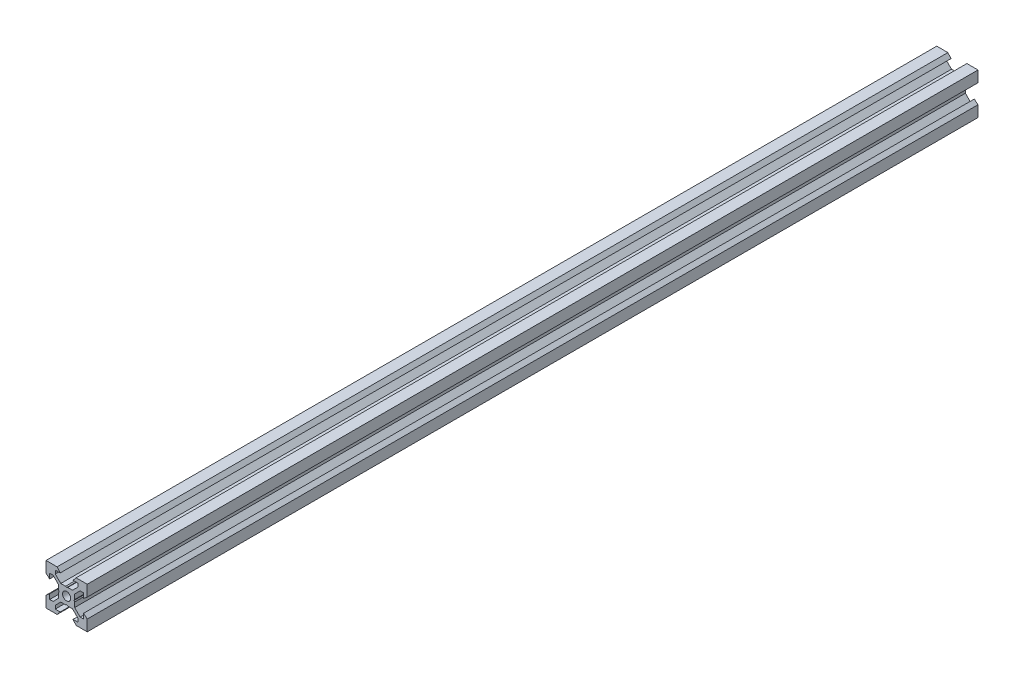
from build123d import *

# Parameters (mm, degrees)
SKETCH1_R           = 2
BOSS_EXTRUDE1_DEPTH = 216


with BuildPart() as part:
    # Sketch1 → Boss-Extrude1 (new body, symmetric)
    with BuildSketch(Plane.XY):
        Polygon((10, 10), (10, 4.610379336), (8.2, 3.1), (8.2, 5.5), (6.560660172, 5.5), (3.9, 2.839339828), (3.9, 0.519615242), (3.6, 0), (3.9, -0.519615242), (3.9, -2.839339828), (6.560660172, -5.5), (8.2, -5.5), (8.2, -3.1), (10, -4.610379336), (10, -10), (4.610379336, -10), (3.1, -8.2), (5.5, -8.2), (5.5, -6.560660172), (2.839339828, -3.9), (0.519615242, -3.9), (0, -3.6), (-0.519615242, -3.9), (-2.839339828, -3.9), (-5.5, -6.560660172), (-5.5, -8.2), (-3.1, -8.2), (-4.610379336, -10), (-10, -10), (-10, -4.610379336), (-8.2, -3.1), (-8.2, -5.5), (-6.560660172, -5.5), (-3.9, -2.839339828), (-3.9, -0.519615242), (-3.6, 0), (-3.9, 0.519615242), (-3.9, 2.839339828), (-6.560660172, 5.5), (-8.2, 5.5), (-8.2, 3.1), (-10, 4.610379336), (-10, 10), (-4.610379336, 10), (-3.1, 8.2), (-5.5, 8.2), (-5.5, 6.560660172), (-2.839339828, 3.9), (-0.519615242, 3.9), (0, 3.6), (0.519615242, 3.9), (2.839339828, 3.9), (5.5, 6.560660172), (5.5, 8.2), (3.1, 8.2), (4.610379336, 10), align=None)
        Circle(SKETCH1_R, mode=Mode.SUBTRACT)
    extrude(amount=BOSS_EXTRUDE1_DEPTH, both=True)


solid = part.part
